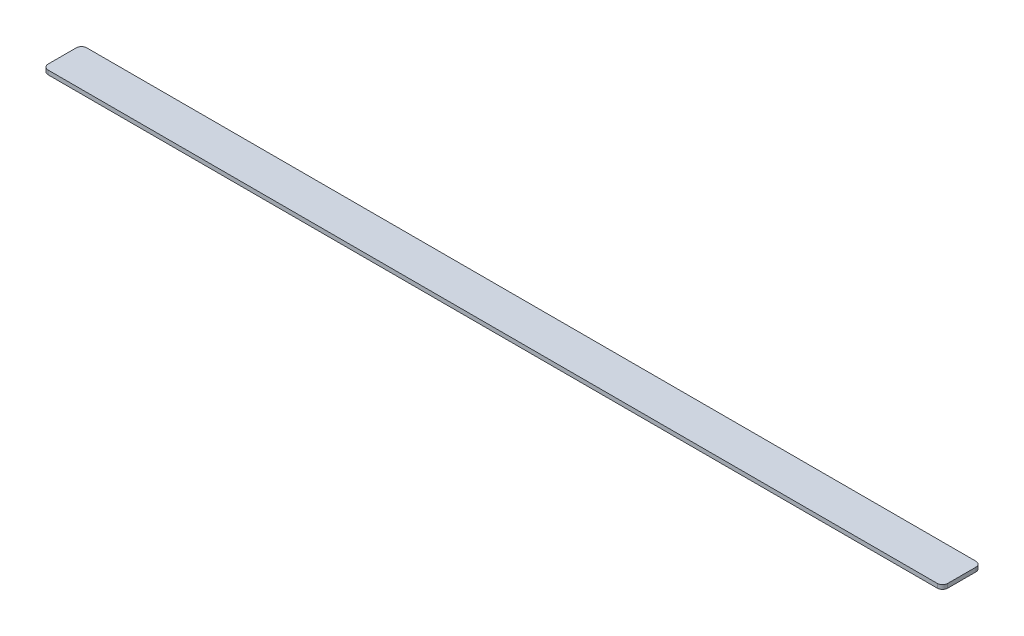
from build123d import *

# Parameters (mm, degrees)
BOSS_EXTRUDE1_DEPTH = 4.76


with BuildPart() as part:
    # Sketch1 → Boss-Extrude1 (new body)
    with BuildSketch(Plane(origin=(0, 0, 0), x_dir=(1, 0, 0), z_dir=(0, 1, 0))):
        with BuildLine():
            Line((6, 0), (1027.5, 0))
            ThreePointArc((1027.5, 0), (1031.742640687, 1.757359313), (1033.5, 6))
            Line((1033.5, 6), (1033.5, 38.3))
            ThreePointArc((1033.5, 38.3), (1031.742640687, 42.542640687), (1027.5, 44.3))
            Line((1027.5, 44.3), (6, 44.3))
            ThreePointArc((6, 44.3), (1.757359313, 42.542640687), (0, 38.3))
            Line((0, 38.3), (0, 6))
            ThreePointArc((0, 6), (1.757359313, 1.757359313), (6, 0))
        make_face()
    extrude(amount=BOSS_EXTRUDE1_DEPTH)


solid = part.part
